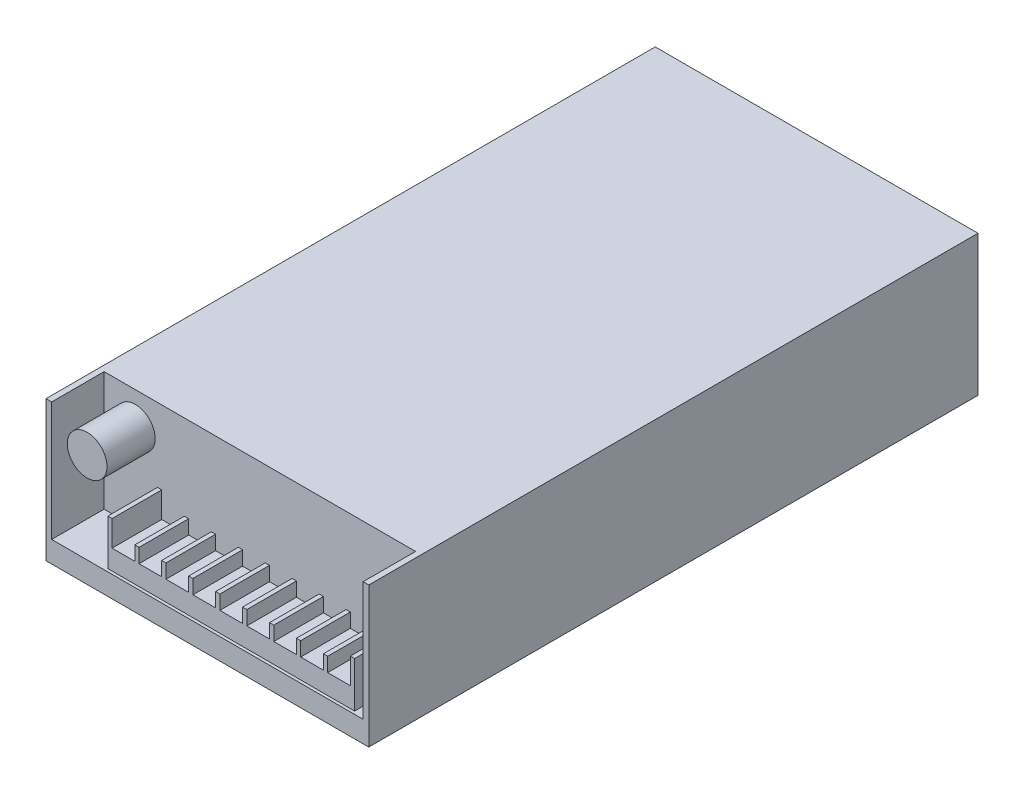
from build123d import *

# Parameters (mm, degrees)
SKETCH1_W           = 113.8
SKETCH1_H           = 214.8
BOSS_EXTRUDE1_DEPTH = 49.5
SKETCH2_W           = 109.8
SKETCH2_H           = 18.5
CUT_EXTRUDE1_DEPTH  = 42
SKETCH3_W           = 87
SKETCH3_H           = 17.5
BOSS_EXTRUDE2_DEPTH = 7
SKETCH4_W           = 1.5
SKETCH4_H           = 17.5
BOSS_EXTRUDE3_DEPTH = 9.05
SKETCH4_3_W         = 1.5
SKETCH4_3_H         = 17.5
BOSS_EXTRUDE4_DEPTH = 5
SKETCH5_R           = 7
BOSS_EXTRUDE5_DEPTH = 17
SKETCH6_R           = 1.5
CUT_EXTRUDE2_DEPTH  = 5


with BuildPart() as part:
    # Sketch1 → Boss-Extrude1 (new body)
    with BuildSketch(Plane(origin=(0, 0, 0), x_dir=(1, 0, 0), z_dir=(0, 1, 0))):
        Rectangle(SKETCH1_W, SKETCH1_H)
    extrude(amount=BOSS_EXTRUDE1_DEPTH)

    # Sketch2 → Cut-Extrude1 (cut)
    with BuildSketch(Plane(origin=(0, 49.5, 0), x_dir=(1, 0, 0), z_dir=(0, 1, 0))):
        with Locations((0, -98.15)):
            Rectangle(SKETCH2_W, SKETCH2_H)
    extrude(amount=-CUT_EXTRUDE1_DEPTH, mode=Mode.SUBTRACT)

    # Sketch3 → Boss-Extrude2 (add)
    with BuildSketch(Plane(origin=(0, 7.5, 0), x_dir=(1, 0, 0), z_dir=(0, 1, 0))):
        with Locations((7.4, -97.65)):
            Rectangle(SKETCH3_W, SKETCH3_H)
    extrude(amount=BOSS_EXTRUDE2_DEPTH)

    # Sketch4 → Boss-Extrude3 (add)
    with BuildSketch(Plane(origin=(0, 14.5, 0), x_dir=(1, 0, 0), z_dir=(0, 1, 0))):
        with Locations((-35.35, -97.65)):
            Rectangle(SKETCH4_W, SKETCH4_H)
        with Locations((50.15, -97.65)):
            Rectangle(SKETCH4_W, SKETCH4_H)
    extrude(amount=BOSS_EXTRUDE3_DEPTH)

    # Sketch4_3 → Boss-Extrude4 (add)
    with BuildSketch(Plane(origin=(0, 14.5, 0), x_dir=(1, 0, 0), z_dir=(0, 1, 0))):
        with Locations((-25.85, -97.65)):
            Rectangle(SKETCH4_3_W, SKETCH4_3_H)
        with Locations((-16.35, -97.65)):
            Rectangle(SKETCH4_3_W, SKETCH4_3_H)
        with Locations((-6.85, -97.65)):
            Rectangle(SKETCH4_3_W, SKETCH4_3_H)
        with Locations((2.65, -97.65)):
            Rectangle(SKETCH4_3_W, SKETCH4_3_H)
        with Locations((12.15, -97.65)):
            Rectangle(SKETCH4_3_W, SKETCH4_3_H)
        with Locations((21.65, -97.65)):
            Rectangle(SKETCH4_3_W, SKETCH4_3_H)
        with Locations((31.15, -97.65)):
            Rectangle(SKETCH4_3_W, SKETCH4_3_H)
        with Locations((40.65, -97.65)):
            Rectangle(SKETCH4_3_W, SKETCH4_3_H)
    extrude(amount=BOSS_EXTRUDE4_DEPTH)

    # Sketch5 → Boss-Extrude5 (add)
    with BuildSketch(Plane.XY.offset(88.9)):
        with Locations((-43.9, 38)):
            Circle(SKETCH5_R)
    extrude(amount=BOSS_EXTRUDE5_DEPTH)

    # Sketch6 → Cut-Extrude2 (cut)
    with BuildSketch(Plane(origin=(0, 0, 0), x_dir=(-1, 0, 0), z_dir=(0, -1, 0))):
        with Locations((-47.8, -80.6)):
            Circle(SKETCH6_R)
        with Locations((-47.8, 97.4)):
            Circle(SKETCH6_R)
        with Locations((47.4, 97.4)):
            Circle(SKETCH6_R)
        with Locations((47.4, -80.6)):
            Circle(SKETCH6_R)
    extrude(amount=-CUT_EXTRUDE2_DEPTH, mode=Mode.SUBTRACT)


solid = part.part
